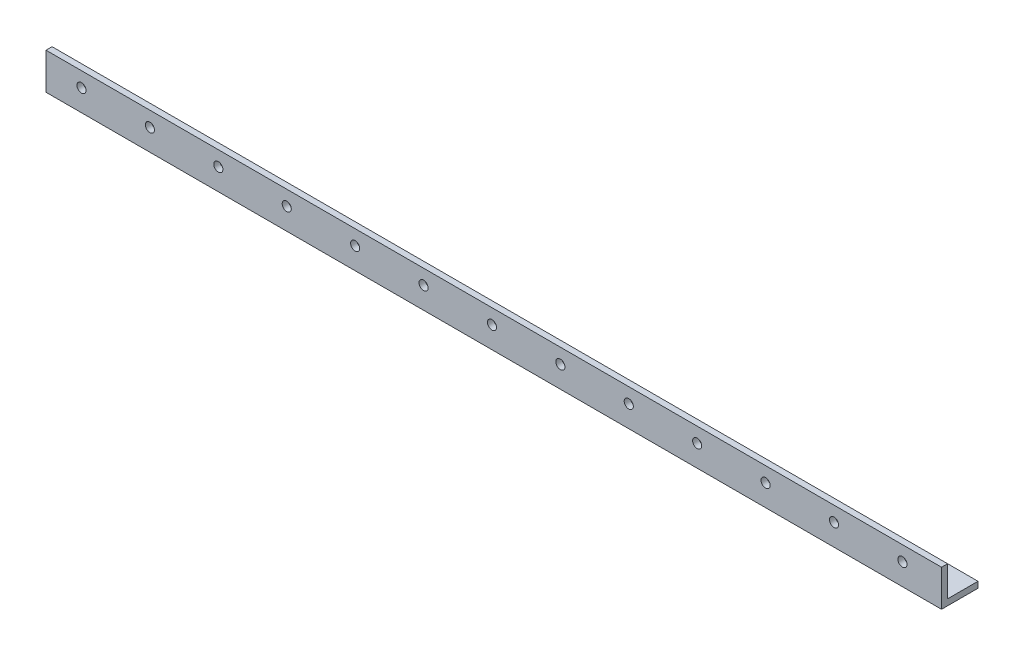
from build123d import *

# Parameters (mm, degrees)
BOSS_EXTRUDE1_DEPTH = 468
SKETCH2_R           = 2.38125
CUT_EXTRUDE1_DEPTH  = 3.175


with BuildPart() as part:
    # Sketch1 → Boss-Extrude1 (new body)
    with BuildSketch(Plane(origin=(0, 0, 0), x_dir=(0, 0, -1), z_dir=(1, 0, 0))):
        Polygon((0, 0), (0, 19.05), (3.175, 19.05), (3.175, 3.175), (19.05, 3.175), (19.05, 0), align=None)
    extrude(amount=-BOSS_EXTRUDE1_DEPTH)

    # Sketch2 → Cut-Extrude1 (cut)
    with BuildSketch(Plane.XY):
        with Locations((-449.45, 11.273546723)):
            Circle(SKETCH2_R)
        with Locations((-413.7, 11.273546723)):
            Circle(SKETCH2_R)
        with Locations((-377.95, 11.273546723)):
            Circle(SKETCH2_R)
        with Locations((-342.2, 11.273546723)):
            Circle(SKETCH2_R)
        with Locations((-306.45, 11.273546723)):
            Circle(SKETCH2_R)
        with Locations((-270.7, 11.273546723)):
            Circle(SKETCH2_R)
        with Locations((-234.95, 11.273546723)):
            Circle(SKETCH2_R)
        with Locations((-199.2, 11.273546723)):
            Circle(SKETCH2_R)
        with Locations((-163.45, 11.273546723)):
            Circle(SKETCH2_R)
        with Locations((-127.7, 11.273546723)):
            Circle(SKETCH2_R)
        with Locations((-91.95, 11.273546723)):
            Circle(SKETCH2_R)
        with Locations((-56.2, 11.273546723)):
            Circle(SKETCH2_R)
        with Locations((-20.45, 11.273546723)):
            Circle(SKETCH2_R)
    extrude(amount=-CUT_EXTRUDE1_DEPTH, mode=Mode.SUBTRACT)


solid = part.part
